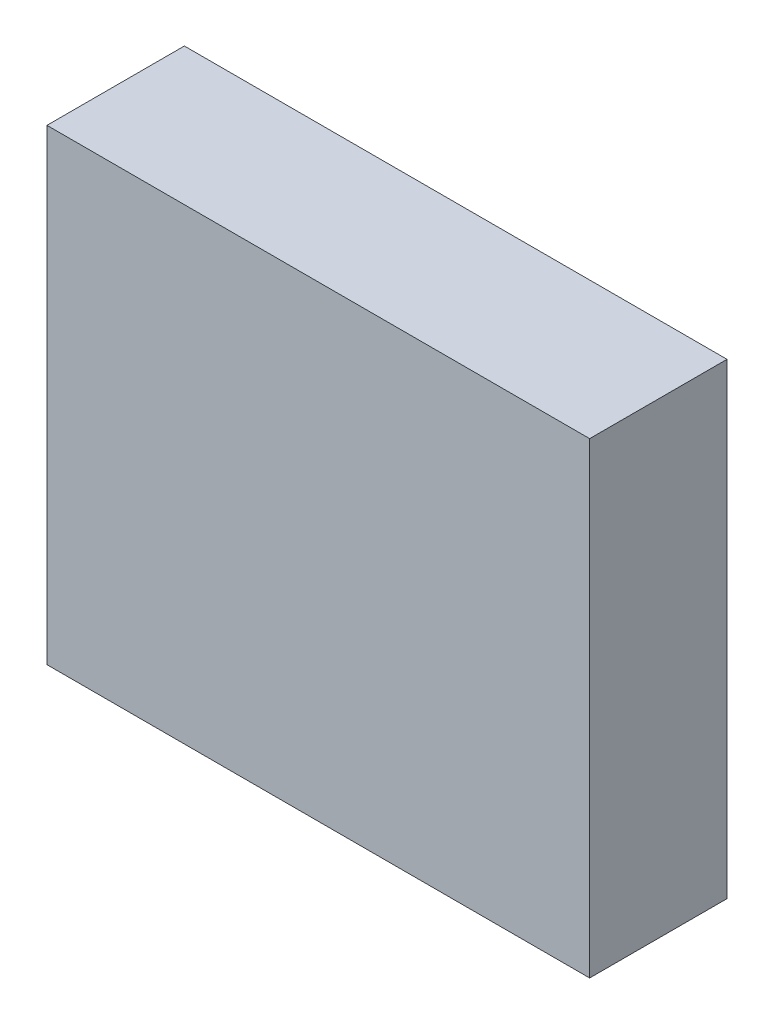
from build123d import *

# Parameters (mm, degrees)
SKETCH1_W            = 79
SKETCH1_H            = 68
MOLD_BASE_DEPTH      = 20
SKETCH2_W            = 69
SKETCH2_H            = 58
MOLD_CUT_DEPTH       = 10
LPATTERN1_COUNT      = 3
LPATTERN1_PITCH      = 10
LPATTERN1_COUNT_DIR2 = 3
LPATTERN1_PITCH_DIR2 = 10
LPATTERN2_COUNT      = 3
LPATTERN2_PITCH      = 10
LPATTERN2_COUNT_DIR2 = 3
LPATTERN2_PITCH_DIR2 = 10


with BuildPart() as part:
    # Sketch1 → Mold Base (new body)
    with BuildSketch(Plane.XY):
        Rectangle(SKETCH1_W, SKETCH1_H)
    extrude(amount=MOLD_BASE_DEPTH)

    # Sketch2 → Mold Cut (cut)
    with BuildSketch(Plane(origin=(0, 0, 0), x_dir=(-1, 0, 0), z_dir=(0, 0, -1))):
        Rectangle(SKETCH2_W, SKETCH2_H)
    extrude(amount=-MOLD_CUT_DEPTH, mode=Mode.SUBTRACT)

    # Sketch3 → Mold (revolve, cut)
    with BuildSketch(Plane(origin=(0, 0, 10), x_dir=(-1, 0, 0), z_dir=(0, 0, -1))):
        with BuildLine():
            Line((0, 2.5), (0, -2.5))
            ThreePointArc((0, -2.5), (2.5, 0), (0, 2.5))
        make_face()
    mold = revolve(axis=Axis((0, 2.5, 10), (0, -1, 0)), mode=Mode.SUBTRACT)

    # LPattern1: Mold 3 × 3
    with Locations(*[(-j * LPATTERN1_PITCH_DIR2, i * LPATTERN1_PITCH, 0) for i in range(LPATTERN1_COUNT) for j in range(LPATTERN1_COUNT_DIR2) if (i, j) != (0, 0)]):
        add(mold, mode=Mode.SUBTRACT)

    # LPattern2: Mold 3 × 3
    with Locations(*[(i * LPATTERN2_PITCH, -j * LPATTERN2_PITCH_DIR2, 0) for i in range(LPATTERN2_COUNT) for j in range(LPATTERN2_COUNT_DIR2) if (i, j) != (0, 0)]):
        add(mold, mode=Mode.SUBTRACT)

    # LPattern2 copy 1 sketch → LPattern2 copy 1 (revolve, cut)
    with BuildSketch(Plane(origin=(-10, -10, 10), x_dir=(-1, 0, 0), z_dir=(0, 0, -1))):
        with BuildLine():
            Line((0, 2.5), (0, -2.5))
            ThreePointArc((0, -2.5), (2.5, 0), (0, 2.5))
        make_face()
    revolve(axis=Axis((-10, -7.5, 10), (0, -1, 0)), mode=Mode.SUBTRACT)

    # LPattern2 copy 2 sketch → LPattern2 copy 2 (revolve, cut)
    with BuildSketch(Plane(origin=(-10, -20, 10), x_dir=(-1, 0, 0), z_dir=(0, 0, -1))):
        with BuildLine():
            Line((0, 2.5), (0, -2.5))
            ThreePointArc((0, -2.5), (2.5, 0), (0, 2.5))
        make_face()
    revolve(axis=Axis((-10, -17.5, 10), (0, -1, 0)), mode=Mode.SUBTRACT)

    # LPattern2 copy 3 sketch → LPattern2 copy 3 (revolve, cut)
    with BuildSketch(Plane(origin=(0, 0, 10), x_dir=(-1, 0, 0), z_dir=(0, 0, -1))):
        with BuildLine():
            Line((0, 2.5), (0, -2.5))
            ThreePointArc((0, -2.5), (2.5, 0), (0, 2.5))
        make_face()
    revolve(axis=Axis((0, 2.5, 10), (0, -1, 0)), mode=Mode.SUBTRACT)

    # LPattern2 copy 4 sketch → LPattern2 copy 4 (revolve, cut)
    with BuildSketch(Plane(origin=(0, -10, 10), x_dir=(-1, 0, 0), z_dir=(0, 0, -1))):
        with BuildLine():
            Line((0, 2.5), (0, -2.5))
            ThreePointArc((0, -2.5), (2.5, 0), (0, 2.5))
        make_face()
    revolve(axis=Axis((0, -7.5, 10), (0, -1, 0)), mode=Mode.SUBTRACT)

    # LPattern2 copy 5 sketch → LPattern2 copy 5 (revolve, cut)
    with BuildSketch(Plane(origin=(0, -20, 10), x_dir=(-1, 0, 0), z_dir=(0, 0, -1))):
        with BuildLine():
            Line((0, 2.5), (0, -2.5))
            ThreePointArc((0, -2.5), (2.5, 0), (0, 2.5))
        make_face()
    revolve(axis=Axis((0, -17.5, 10), (0, -1, 0)), mode=Mode.SUBTRACT)

    # LPattern2 copy 6 sketch → LPattern2 copy 6 (revolve, cut)
    with BuildSketch(Plane(origin=(10, 0, 10), x_dir=(-1, 0, 0), z_dir=(0, 0, -1))):
        with BuildLine():
            Line((0, 2.5), (0, -2.5))
            ThreePointArc((0, -2.5), (2.5, 0), (0, 2.5))
        make_face()
    revolve(axis=Axis((10, 2.5, 10), (0, -1, 0)), mode=Mode.SUBTRACT)

    # LPattern2 copy 7 sketch → LPattern2 copy 7 (revolve, cut)
    with BuildSketch(Plane(origin=(10, -10, 10), x_dir=(-1, 0, 0), z_dir=(0, 0, -1))):
        with BuildLine():
            Line((0, 2.5), (0, -2.5))
            ThreePointArc((0, -2.5), (2.5, 0), (0, 2.5))
        make_face()
    revolve(axis=Axis((10, -7.5, 10), (0, -1, 0)), mode=Mode.SUBTRACT)

    # LPattern2 copy 8 sketch → LPattern2 copy 8 (revolve, cut)
    with BuildSketch(Plane(origin=(10, -20, 10), x_dir=(-1, 0, 0), z_dir=(0, 0, -1))):
        with BuildLine():
            Line((0, 2.5), (0, -2.5))
            ThreePointArc((0, -2.5), (2.5, 0), (0, 2.5))
        make_face()
    revolve(axis=Axis((10, -17.5, 10), (0, -1, 0)), mode=Mode.SUBTRACT)

    # LPattern2 copy 9 sketch → LPattern2 copy 9 (revolve, cut)
    with BuildSketch(Plane(origin=(-20, -10, 10), x_dir=(-1, 0, 0), z_dir=(0, 0, -1))):
        with BuildLine():
            Line((0, 2.5), (0, -2.5))
            ThreePointArc((0, -2.5), (2.5, 0), (0, 2.5))
        make_face()
    revolve(axis=Axis((-20, -7.5, 10), (0, -1, 0)), mode=Mode.SUBTRACT)

    # LPattern2 copy 10 sketch → LPattern2 copy 10 (revolve, cut)
    with BuildSketch(Plane(origin=(-20, -20, 10), x_dir=(-1, 0, 0), z_dir=(0, 0, -1))):
        with BuildLine():
            Line((0, 2.5), (0, -2.5))
            ThreePointArc((0, -2.5), (2.5, 0), (0, 2.5))
        make_face()
    revolve(axis=Axis((-20, -17.5, 10), (0, -1, 0)), mode=Mode.SUBTRACT)

    # LPattern2 copy 11 sketch → LPattern2 copy 11 (revolve, cut)
    with BuildSketch(Plane(origin=(-10, 0, 10), x_dir=(-1, 0, 0), z_dir=(0, 0, -1))):
        with BuildLine():
            Line((0, 2.5), (0, -2.5))
            ThreePointArc((0, -2.5), (2.5, 0), (0, 2.5))
        make_face()
    revolve(axis=Axis((-10, 2.5, 10), (0, -1, 0)), mode=Mode.SUBTRACT)

    # LPattern2 copy 12 sketch → LPattern2 copy 12 (revolve, cut)
    with BuildSketch(Plane(origin=(-10, -10, 10), x_dir=(-1, 0, 0), z_dir=(0, 0, -1))):
        with BuildLine():
            Line((0, 2.5), (0, -2.5))
            ThreePointArc((0, -2.5), (2.5, 0), (0, 2.5))
        make_face()
    revolve(axis=Axis((-10, -7.5, 10), (0, -1, 0)), mode=Mode.SUBTRACT)

    # LPattern2 copy 13 sketch → LPattern2 copy 13 (revolve, cut)
    with BuildSketch(Plane(origin=(-10, -20, 10), x_dir=(-1, 0, 0), z_dir=(0, 0, -1))):
        with BuildLine():
            Line((0, 2.5), (0, -2.5))
            ThreePointArc((0, -2.5), (2.5, 0), (0, 2.5))
        make_face()
    revolve(axis=Axis((-10, -17.5, 10), (0, -1, 0)), mode=Mode.SUBTRACT)

    # LPattern2 copy 14 sketch → LPattern2 copy 14 (revolve, cut)
    with BuildSketch(Plane(origin=(0, 0, 10), x_dir=(-1, 0, 0), z_dir=(0, 0, -1))):
        with BuildLine():
            Line((0, 2.5), (0, -2.5))
            ThreePointArc((0, -2.5), (2.5, 0), (0, 2.5))
        make_face()
    revolve(axis=Axis((0, 2.5, 10), (0, -1, 0)), mode=Mode.SUBTRACT)

    # LPattern2 copy 15 sketch → LPattern2 copy 15 (revolve, cut)
    with BuildSketch(Plane(origin=(0, -10, 10), x_dir=(-1, 0, 0), z_dir=(0, 0, -1))):
        with BuildLine():
            Line((0, 2.5), (0, -2.5))
            ThreePointArc((0, -2.5), (2.5, 0), (0, 2.5))
        make_face()
    revolve(axis=Axis((0, -7.5, 10), (0, -1, 0)), mode=Mode.SUBTRACT)

    # LPattern2 copy 16 sketch → LPattern2 copy 16 (revolve, cut)
    with BuildSketch(Plane(origin=(0, -20, 10), x_dir=(-1, 0, 0), z_dir=(0, 0, -1))):
        with BuildLine():
            Line((0, 2.5), (0, -2.5))
            ThreePointArc((0, -2.5), (2.5, 0), (0, 2.5))
        make_face()
    revolve(axis=Axis((0, -17.5, 10), (0, -1, 0)), mode=Mode.SUBTRACT)

    # LPattern2 copy 17 sketch → LPattern2 copy 17 (revolve, cut)
    with BuildSketch(Plane(origin=(0, 0, 10), x_dir=(-1, 0, 0), z_dir=(0, 0, -1))):
        with BuildLine():
            Line((0, 2.5), (0, -2.5))
            ThreePointArc((0, -2.5), (2.5, 0), (0, 2.5))
        make_face()
    revolve(axis=Axis((0, 2.5, 10), (0, -1, 0)), mode=Mode.SUBTRACT)

    # LPattern2 copy 18 sketch → LPattern2 copy 18 (revolve, cut)
    with BuildSketch(Plane(origin=(0, -10, 10), x_dir=(-1, 0, 0), z_dir=(0, 0, -1))):
        with BuildLine():
            Line((0, 2.5), (0, -2.5))
            ThreePointArc((0, -2.5), (2.5, 0), (0, 2.5))
        make_face()
    revolve(axis=Axis((0, -7.5, 10), (0, -1, 0)), mode=Mode.SUBTRACT)

    # LPattern2 copy 19 sketch → LPattern2 copy 19 (revolve, cut)
    with BuildSketch(Plane(origin=(10, 10, 10), x_dir=(-1, 0, 0), z_dir=(0, 0, -1))):
        with BuildLine():
            Line((0, 2.5), (0, -2.5))
            ThreePointArc((0, -2.5), (2.5, 0), (0, 2.5))
        make_face()
    revolve(axis=Axis((10, 12.5, 10), (0, -1, 0)), mode=Mode.SUBTRACT)

    # LPattern2 copy 20 sketch → LPattern2 copy 20 (revolve, cut)
    with BuildSketch(Plane(origin=(10, 0, 10), x_dir=(-1, 0, 0), z_dir=(0, 0, -1))):
        with BuildLine():
            Line((0, 2.5), (0, -2.5))
            ThreePointArc((0, -2.5), (2.5, 0), (0, 2.5))
        make_face()
    revolve(axis=Axis((10, 2.5, 10), (0, -1, 0)), mode=Mode.SUBTRACT)

    # LPattern2 copy 21 sketch → LPattern2 copy 21 (revolve, cut)
    with BuildSketch(Plane(origin=(10, -10, 10), x_dir=(-1, 0, 0), z_dir=(0, 0, -1))):
        with BuildLine():
            Line((0, 2.5), (0, -2.5))
            ThreePointArc((0, -2.5), (2.5, 0), (0, 2.5))
        make_face()
    revolve(axis=Axis((10, -7.5, 10), (0, -1, 0)), mode=Mode.SUBTRACT)

    # LPattern2 copy 22 sketch → LPattern2 copy 22 (revolve, cut)
    with BuildSketch(Plane(origin=(20, 10, 10), x_dir=(-1, 0, 0), z_dir=(0, 0, -1))):
        with BuildLine():
            Line((0, 2.5), (0, -2.5))
            ThreePointArc((0, -2.5), (2.5, 0), (0, 2.5))
        make_face()
    revolve(axis=Axis((20, 12.5, 10), (0, -1, 0)), mode=Mode.SUBTRACT)

    # LPattern2 copy 23 sketch → LPattern2 copy 23 (revolve, cut)
    with BuildSketch(Plane(origin=(20, 0, 10), x_dir=(-1, 0, 0), z_dir=(0, 0, -1))):
        with BuildLine():
            Line((0, 2.5), (0, -2.5))
            ThreePointArc((0, -2.5), (2.5, 0), (0, 2.5))
        make_face()
    revolve(axis=Axis((20, 2.5, 10), (0, -1, 0)), mode=Mode.SUBTRACT)

    # LPattern2 copy 24 sketch → LPattern2 copy 24 (revolve, cut)
    with BuildSketch(Plane(origin=(20, -10, 10), x_dir=(-1, 0, 0), z_dir=(0, 0, -1))):
        with BuildLine():
            Line((0, 2.5), (0, -2.5))
            ThreePointArc((0, -2.5), (2.5, 0), (0, 2.5))
        make_face()
    revolve(axis=Axis((20, -7.5, 10), (0, -1, 0)), mode=Mode.SUBTRACT)

    # LPattern2 copy 25 sketch → LPattern2 copy 25 (revolve, cut)
    with BuildSketch(Plane(origin=(-10, 0, 10), x_dir=(-1, 0, 0), z_dir=(0, 0, -1))):
        with BuildLine():
            Line((0, 2.5), (0, -2.5))
            ThreePointArc((0, -2.5), (2.5, 0), (0, 2.5))
        make_face()
    revolve(axis=Axis((-10, 2.5, 10), (0, -1, 0)), mode=Mode.SUBTRACT)

    # LPattern2 copy 26 sketch → LPattern2 copy 26 (revolve, cut)
    with BuildSketch(Plane(origin=(-10, -10, 10), x_dir=(-1, 0, 0), z_dir=(0, 0, -1))):
        with BuildLine():
            Line((0, 2.5), (0, -2.5))
            ThreePointArc((0, -2.5), (2.5, 0), (0, 2.5))
        make_face()
    revolve(axis=Axis((-10, -7.5, 10), (0, -1, 0)), mode=Mode.SUBTRACT)

    # LPattern2 copy 27 sketch → LPattern2 copy 27 (revolve, cut)
    with BuildSketch(Plane(origin=(0, 10, 10), x_dir=(-1, 0, 0), z_dir=(0, 0, -1))):
        with BuildLine():
            Line((0, 2.5), (0, -2.5))
            ThreePointArc((0, -2.5), (2.5, 0), (0, 2.5))
        make_face()
    revolve(axis=Axis((0, 12.5, 10), (0, -1, 0)), mode=Mode.SUBTRACT)

    # LPattern2 copy 28 sketch → LPattern2 copy 28 (revolve, cut)
    with BuildSketch(Plane(origin=(0, 0, 10), x_dir=(-1, 0, 0), z_dir=(0, 0, -1))):
        with BuildLine():
            Line((0, 2.5), (0, -2.5))
            ThreePointArc((0, -2.5), (2.5, 0), (0, 2.5))
        make_face()
    revolve(axis=Axis((0, 2.5, 10), (0, -1, 0)), mode=Mode.SUBTRACT)

    # LPattern2 copy 29 sketch → LPattern2 copy 29 (revolve, cut)
    with BuildSketch(Plane(origin=(0, -10, 10), x_dir=(-1, 0, 0), z_dir=(0, 0, -1))):
        with BuildLine():
            Line((0, 2.5), (0, -2.5))
            ThreePointArc((0, -2.5), (2.5, 0), (0, 2.5))
        make_face()
    revolve(axis=Axis((0, -7.5, 10), (0, -1, 0)), mode=Mode.SUBTRACT)

    # LPattern2 copy 30 sketch → LPattern2 copy 30 (revolve, cut)
    with BuildSketch(Plane(origin=(10, 10, 10), x_dir=(-1, 0, 0), z_dir=(0, 0, -1))):
        with BuildLine():
            Line((0, 2.5), (0, -2.5))
            ThreePointArc((0, -2.5), (2.5, 0), (0, 2.5))
        make_face()
    revolve(axis=Axis((10, 12.5, 10), (0, -1, 0)), mode=Mode.SUBTRACT)

    # LPattern2 copy 31 sketch → LPattern2 copy 31 (revolve, cut)
    with BuildSketch(Plane(origin=(10, 0, 10), x_dir=(-1, 0, 0), z_dir=(0, 0, -1))):
        with BuildLine():
            Line((0, 2.5), (0, -2.5))
            ThreePointArc((0, -2.5), (2.5, 0), (0, 2.5))
        make_face()
    revolve(axis=Axis((10, 2.5, 10), (0, -1, 0)), mode=Mode.SUBTRACT)

    # LPattern2 copy 32 sketch → LPattern2 copy 32 (revolve, cut)
    with BuildSketch(Plane(origin=(10, -10, 10), x_dir=(-1, 0, 0), z_dir=(0, 0, -1))):
        with BuildLine():
            Line((0, 2.5), (0, -2.5))
            ThreePointArc((0, -2.5), (2.5, 0), (0, 2.5))
        make_face()
    revolve(axis=Axis((10, -7.5, 10), (0, -1, 0)), mode=Mode.SUBTRACT)

    # LPattern2 copy 33 sketch → LPattern2 copy 33 (revolve, cut)
    with BuildSketch(Plane(origin=(-20, 0, 10), x_dir=(-1, 0, 0), z_dir=(0, 0, -1))):
        with BuildLine():
            Line((0, 2.5), (0, -2.5))
            ThreePointArc((0, -2.5), (2.5, 0), (0, 2.5))
        make_face()
    revolve(axis=Axis((-20, 2.5, 10), (0, -1, 0)), mode=Mode.SUBTRACT)

    # LPattern2 copy 34 sketch → LPattern2 copy 34 (revolve, cut)
    with BuildSketch(Plane(origin=(-20, -10, 10), x_dir=(-1, 0, 0), z_dir=(0, 0, -1))):
        with BuildLine():
            Line((0, 2.5), (0, -2.5))
            ThreePointArc((0, -2.5), (2.5, 0), (0, 2.5))
        make_face()
    revolve(axis=Axis((-20, -7.5, 10), (0, -1, 0)), mode=Mode.SUBTRACT)

    # LPattern2 copy 35 sketch → LPattern2 copy 35 (revolve, cut)
    with BuildSketch(Plane(origin=(-10, 10, 10), x_dir=(-1, 0, 0), z_dir=(0, 0, -1))):
        with BuildLine():
            Line((0, 2.5), (0, -2.5))
            ThreePointArc((0, -2.5), (2.5, 0), (0, 2.5))
        make_face()
    revolve(axis=Axis((-10, 12.5, 10), (0, -1, 0)), mode=Mode.SUBTRACT)

    # LPattern2 copy 36 sketch → LPattern2 copy 36 (revolve, cut)
    with BuildSketch(Plane(origin=(-10, 0, 10), x_dir=(-1, 0, 0), z_dir=(0, 0, -1))):
        with BuildLine():
            Line((0, 2.5), (0, -2.5))
            ThreePointArc((0, -2.5), (2.5, 0), (0, 2.5))
        make_face()
    revolve(axis=Axis((-10, 2.5, 10), (0, -1, 0)), mode=Mode.SUBTRACT)

    # LPattern2 copy 37 sketch → LPattern2 copy 37 (revolve, cut)
    with BuildSketch(Plane(origin=(-10, -10, 10), x_dir=(-1, 0, 0), z_dir=(0, 0, -1))):
        with BuildLine():
            Line((0, 2.5), (0, -2.5))
            ThreePointArc((0, -2.5), (2.5, 0), (0, 2.5))
        make_face()
    revolve(axis=Axis((-10, -7.5, 10), (0, -1, 0)), mode=Mode.SUBTRACT)

    # LPattern2 copy 38 sketch → LPattern2 copy 38 (revolve, cut)
    with BuildSketch(Plane(origin=(0, 10, 10), x_dir=(-1, 0, 0), z_dir=(0, 0, -1))):
        with BuildLine():
            Line((0, 2.5), (0, -2.5))
            ThreePointArc((0, -2.5), (2.5, 0), (0, 2.5))
        make_face()
    revolve(axis=Axis((0, 12.5, 10), (0, -1, 0)), mode=Mode.SUBTRACT)

    # LPattern2 copy 39 sketch → LPattern2 copy 39 (revolve, cut)
    with BuildSketch(Plane(origin=(0, 0, 10), x_dir=(-1, 0, 0), z_dir=(0, 0, -1))):
        with BuildLine():
            Line((0, 2.5), (0, -2.5))
            ThreePointArc((0, -2.5), (2.5, 0), (0, 2.5))
        make_face()
    revolve(axis=Axis((0, 2.5, 10), (0, -1, 0)), mode=Mode.SUBTRACT)

    # LPattern2 copy 40 sketch → LPattern2 copy 40 (revolve, cut)
    with BuildSketch(Plane(origin=(0, -10, 10), x_dir=(-1, 0, 0), z_dir=(0, 0, -1))):
        with BuildLine():
            Line((0, 2.5), (0, -2.5))
            ThreePointArc((0, -2.5), (2.5, 0), (0, 2.5))
        make_face()
    revolve(axis=Axis((0, -7.5, 10), (0, -1, 0)), mode=Mode.SUBTRACT)

    # LPattern2 copy 41 sketch → LPattern2 copy 41 (revolve, cut)
    with BuildSketch(Plane(origin=(0, 10, 10), x_dir=(-1, 0, 0), z_dir=(0, 0, -1))):
        with BuildLine():
            Line((0, 2.5), (0, -2.5))
            ThreePointArc((0, -2.5), (2.5, 0), (0, 2.5))
        make_face()
    revolve(axis=Axis((0, 12.5, 10), (0, -1, 0)), mode=Mode.SUBTRACT)

    # LPattern2 copy 42 sketch → LPattern2 copy 42 (revolve, cut)
    with BuildSketch(Plane(origin=(0, 0, 10), x_dir=(-1, 0, 0), z_dir=(0, 0, -1))):
        with BuildLine():
            Line((0, 2.5), (0, -2.5))
            ThreePointArc((0, -2.5), (2.5, 0), (0, 2.5))
        make_face()
    revolve(axis=Axis((0, 2.5, 10), (0, -1, 0)), mode=Mode.SUBTRACT)

    # LPattern2 copy 43 sketch → LPattern2 copy 43 (revolve, cut)
    with BuildSketch(Plane(origin=(10, 20, 10), x_dir=(-1, 0, 0), z_dir=(0, 0, -1))):
        with BuildLine():
            Line((0, 2.5), (0, -2.5))
            ThreePointArc((0, -2.5), (2.5, 0), (0, 2.5))
        make_face()
    revolve(axis=Axis((10, 22.5, 10), (0, -1, 0)), mode=Mode.SUBTRACT)

    # LPattern2 copy 44 sketch → LPattern2 copy 44 (revolve, cut)
    with BuildSketch(Plane(origin=(10, 10, 10), x_dir=(-1, 0, 0), z_dir=(0, 0, -1))):
        with BuildLine():
            Line((0, 2.5), (0, -2.5))
            ThreePointArc((0, -2.5), (2.5, 0), (0, 2.5))
        make_face()
    revolve(axis=Axis((10, 12.5, 10), (0, -1, 0)), mode=Mode.SUBTRACT)

    # LPattern2 copy 45 sketch → LPattern2 copy 45 (revolve, cut)
    with BuildSketch(Plane(origin=(10, 0, 10), x_dir=(-1, 0, 0), z_dir=(0, 0, -1))):
        with BuildLine():
            Line((0, 2.5), (0, -2.5))
            ThreePointArc((0, -2.5), (2.5, 0), (0, 2.5))
        make_face()
    revolve(axis=Axis((10, 2.5, 10), (0, -1, 0)), mode=Mode.SUBTRACT)

    # LPattern2 copy 46 sketch → LPattern2 copy 46 (revolve, cut)
    with BuildSketch(Plane(origin=(20, 20, 10), x_dir=(-1, 0, 0), z_dir=(0, 0, -1))):
        with BuildLine():
            Line((0, 2.5), (0, -2.5))
            ThreePointArc((0, -2.5), (2.5, 0), (0, 2.5))
        make_face()
    revolve(axis=Axis((20, 22.5, 10), (0, -1, 0)), mode=Mode.SUBTRACT)

    # LPattern2 copy 47 sketch → LPattern2 copy 47 (revolve, cut)
    with BuildSketch(Plane(origin=(20, 10, 10), x_dir=(-1, 0, 0), z_dir=(0, 0, -1))):
        with BuildLine():
            Line((0, 2.5), (0, -2.5))
            ThreePointArc((0, -2.5), (2.5, 0), (0, 2.5))
        make_face()
    revolve(axis=Axis((20, 12.5, 10), (0, -1, 0)), mode=Mode.SUBTRACT)

    # LPattern2 copy 48 sketch → LPattern2 copy 48 (revolve, cut)
    with BuildSketch(Plane(origin=(20, 0, 10), x_dir=(-1, 0, 0), z_dir=(0, 0, -1))):
        with BuildLine():
            Line((0, 2.5), (0, -2.5))
            ThreePointArc((0, -2.5), (2.5, 0), (0, 2.5))
        make_face()
    revolve(axis=Axis((20, 2.5, 10), (0, -1, 0)), mode=Mode.SUBTRACT)

    # LPattern2 copy 49 sketch → LPattern2 copy 49 (revolve, cut)
    with BuildSketch(Plane(origin=(-10, 10, 10), x_dir=(-1, 0, 0), z_dir=(0, 0, -1))):
        with BuildLine():
            Line((0, 2.5), (0, -2.5))
            ThreePointArc((0, -2.5), (2.5, 0), (0, 2.5))
        make_face()
    revolve(axis=Axis((-10, 12.5, 10), (0, -1, 0)), mode=Mode.SUBTRACT)

    # LPattern2 copy 50 sketch → LPattern2 copy 50 (revolve, cut)
    with BuildSketch(Plane(origin=(-10, 0, 10), x_dir=(-1, 0, 0), z_dir=(0, 0, -1))):
        with BuildLine():
            Line((0, 2.5), (0, -2.5))
            ThreePointArc((0, -2.5), (2.5, 0), (0, 2.5))
        make_face()
    revolve(axis=Axis((-10, 2.5, 10), (0, -1, 0)), mode=Mode.SUBTRACT)

    # LPattern2 copy 51 sketch → LPattern2 copy 51 (revolve, cut)
    with BuildSketch(Plane(origin=(0, 20, 10), x_dir=(-1, 0, 0), z_dir=(0, 0, -1))):
        with BuildLine():
            Line((0, 2.5), (0, -2.5))
            ThreePointArc((0, -2.5), (2.5, 0), (0, 2.5))
        make_face()
    revolve(axis=Axis((0, 22.5, 10), (0, -1, 0)), mode=Mode.SUBTRACT)

    # LPattern2 copy 52 sketch → LPattern2 copy 52 (revolve, cut)
    with BuildSketch(Plane(origin=(0, 10, 10), x_dir=(-1, 0, 0), z_dir=(0, 0, -1))):
        with BuildLine():
            Line((0, 2.5), (0, -2.5))
            ThreePointArc((0, -2.5), (2.5, 0), (0, 2.5))
        make_face()
    revolve(axis=Axis((0, 12.5, 10), (0, -1, 0)), mode=Mode.SUBTRACT)

    # LPattern2 copy 53 sketch → LPattern2 copy 53 (revolve, cut)
    with BuildSketch(Plane(origin=(0, 0, 10), x_dir=(-1, 0, 0), z_dir=(0, 0, -1))):
        with BuildLine():
            Line((0, 2.5), (0, -2.5))
            ThreePointArc((0, -2.5), (2.5, 0), (0, 2.5))
        make_face()
    revolve(axis=Axis((0, 2.5, 10), (0, -1, 0)), mode=Mode.SUBTRACT)

    # LPattern2 copy 54 sketch → LPattern2 copy 54 (revolve, cut)
    with BuildSketch(Plane(origin=(10, 20, 10), x_dir=(-1, 0, 0), z_dir=(0, 0, -1))):
        with BuildLine():
            Line((0, 2.5), (0, -2.5))
            ThreePointArc((0, -2.5), (2.5, 0), (0, 2.5))
        make_face()
    revolve(axis=Axis((10, 22.5, 10), (0, -1, 0)), mode=Mode.SUBTRACT)

    # LPattern2 copy 55 sketch → LPattern2 copy 55 (revolve, cut)
    with BuildSketch(Plane(origin=(10, 10, 10), x_dir=(-1, 0, 0), z_dir=(0, 0, -1))):
        with BuildLine():
            Line((0, 2.5), (0, -2.5))
            ThreePointArc((0, -2.5), (2.5, 0), (0, 2.5))
        make_face()
    revolve(axis=Axis((10, 12.5, 10), (0, -1, 0)), mode=Mode.SUBTRACT)

    # LPattern2 copy 56 sketch → LPattern2 copy 56 (revolve, cut)
    with BuildSketch(Plane(origin=(10, 0, 10), x_dir=(-1, 0, 0), z_dir=(0, 0, -1))):
        with BuildLine():
            Line((0, 2.5), (0, -2.5))
            ThreePointArc((0, -2.5), (2.5, 0), (0, 2.5))
        make_face()
    revolve(axis=Axis((10, 2.5, 10), (0, -1, 0)), mode=Mode.SUBTRACT)

    # LPattern2 copy 57 sketch → LPattern2 copy 57 (revolve, cut)
    with BuildSketch(Plane(origin=(-20, 10, 10), x_dir=(-1, 0, 0), z_dir=(0, 0, -1))):
        with BuildLine():
            Line((0, 2.5), (0, -2.5))
            ThreePointArc((0, -2.5), (2.5, 0), (0, 2.5))
        make_face()
    revolve(axis=Axis((-20, 12.5, 10), (0, -1, 0)), mode=Mode.SUBTRACT)

    # LPattern2 copy 58 sketch → LPattern2 copy 58 (revolve, cut)
    with BuildSketch(Plane(origin=(-20, 0, 10), x_dir=(-1, 0, 0), z_dir=(0, 0, -1))):
        with BuildLine():
            Line((0, 2.5), (0, -2.5))
            ThreePointArc((0, -2.5), (2.5, 0), (0, 2.5))
        make_face()
    revolve(axis=Axis((-20, 2.5, 10), (0, -1, 0)), mode=Mode.SUBTRACT)

    # LPattern2 copy 59 sketch → LPattern2 copy 59 (revolve, cut)
    with BuildSketch(Plane(origin=(-10, 20, 10), x_dir=(-1, 0, 0), z_dir=(0, 0, -1))):
        with BuildLine():
            Line((0, 2.5), (0, -2.5))
            ThreePointArc((0, -2.5), (2.5, 0), (0, 2.5))
        make_face()
    revolve(axis=Axis((-10, 22.5, 10), (0, -1, 0)), mode=Mode.SUBTRACT)

    # LPattern2 copy 60 sketch → LPattern2 copy 60 (revolve, cut)
    with BuildSketch(Plane(origin=(-10, 10, 10), x_dir=(-1, 0, 0), z_dir=(0, 0, -1))):
        with BuildLine():
            Line((0, 2.5), (0, -2.5))
            ThreePointArc((0, -2.5), (2.5, 0), (0, 2.5))
        make_face()
    revolve(axis=Axis((-10, 12.5, 10), (0, -1, 0)), mode=Mode.SUBTRACT)

    # LPattern2 copy 61 sketch → LPattern2 copy 61 (revolve, cut)
    with BuildSketch(Plane(origin=(-10, 0, 10), x_dir=(-1, 0, 0), z_dir=(0, 0, -1))):
        with BuildLine():
            Line((0, 2.5), (0, -2.5))
            ThreePointArc((0, -2.5), (2.5, 0), (0, 2.5))
        make_face()
    revolve(axis=Axis((-10, 2.5, 10), (0, -1, 0)), mode=Mode.SUBTRACT)

    # LPattern2 copy 62 sketch → LPattern2 copy 62 (revolve, cut)
    with BuildSketch(Plane(origin=(0, 20, 10), x_dir=(-1, 0, 0), z_dir=(0, 0, -1))):
        with BuildLine():
            Line((0, 2.5), (0, -2.5))
            ThreePointArc((0, -2.5), (2.5, 0), (0, 2.5))
        make_face()
    revolve(axis=Axis((0, 22.5, 10), (0, -1, 0)), mode=Mode.SUBTRACT)

    # LPattern2 copy 63 sketch → LPattern2 copy 63 (revolve, cut)
    with BuildSketch(Plane(origin=(0, 10, 10), x_dir=(-1, 0, 0), z_dir=(0, 0, -1))):
        with BuildLine():
            Line((0, 2.5), (0, -2.5))
            ThreePointArc((0, -2.5), (2.5, 0), (0, 2.5))
        make_face()
    revolve(axis=Axis((0, 12.5, 10), (0, -1, 0)), mode=Mode.SUBTRACT)

    # LPattern2 copy 64 sketch → LPattern2 copy 64 (revolve, cut)
    with BuildSketch(Plane(origin=(0, 0, 10), x_dir=(-1, 0, 0), z_dir=(0, 0, -1))):
        with BuildLine():
            Line((0, 2.5), (0, -2.5))
            ThreePointArc((0, -2.5), (2.5, 0), (0, 2.5))
        make_face()
    revolve(axis=Axis((0, 2.5, 10), (0, -1, 0)), mode=Mode.SUBTRACT)


solid = part.part
